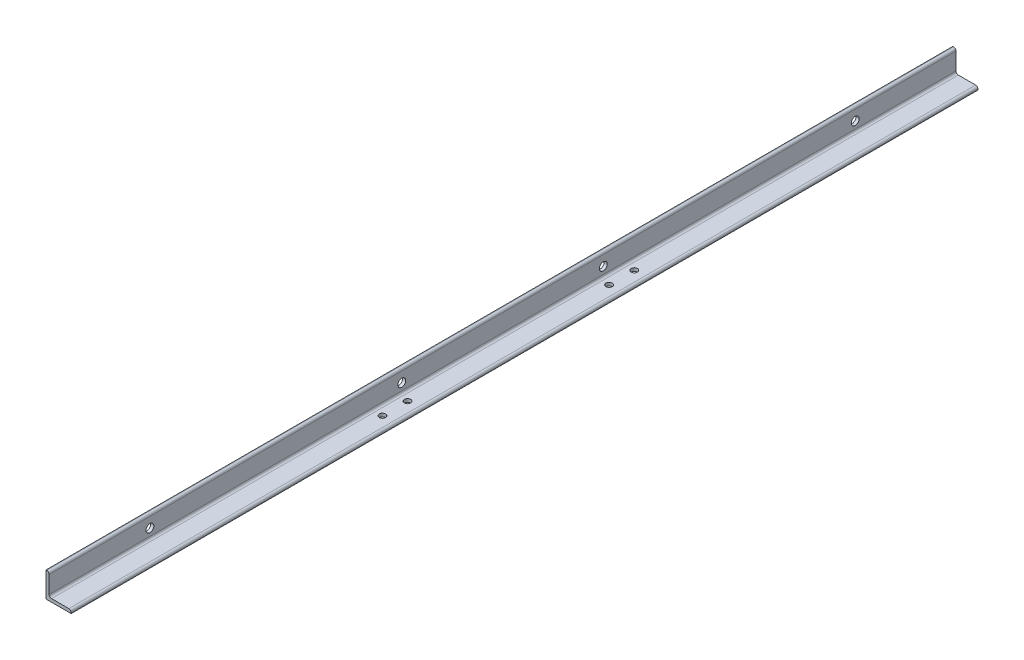
from build123d import *

# Parameters (mm, degrees)
BOSS_EXTRUDE1_DEPTH                 = 914.4
F_13_16_0_8125_DIAMETER_HOLE1_D     = 12.7
F_13_16_0_8125_DIAMETER_HOLE1_DEPTH = 6.35
F_5_8_0_625_DIAMETER_HOLE1_D        = 15.875
F_5_8_0_625_DIAMETER_HOLE1_DEPTH    = 6.35
SKETCH7_R                           = 6.35
CUT_EXTRUDE1_DEPTH                  = 7.35


with BuildPart() as part:
    # Sketch1 → Boss-Extrude1 (new body, symmetric)
    with BuildSketch(Plane.XY):
        with BuildLine():
            Line((0, 0), (0, 50.8))
            Line((0, 50.8), (1.59258, 50.8))
            ThreePointArc((1.59258, 50.8), (4.956583943, 49.406583943), (6.35, 46.04258))
            Line((6.35, 46.04258), (6.35, 11.1125))
            ThreePointArc((6.35, 11.1125), (7.744903955, 7.744903955), (11.1125, 6.35))
            Line((11.1125, 6.35), (46.04258, 6.35))
            ThreePointArc((46.04258, 6.35), (49.406583943, 4.956583943), (50.8, 1.59258))
            Line((50.8, 1.59258), (50.8, 0))
            Line((50.8, 0), (0, 0))
        make_face()
    extrude(amount=BOSS_EXTRUDE1_DEPTH, both=True)

    # 13/16 (0.8125) Diameter Hole1
    with Locations(Plane.XZ):
        with Locations((25.4, -195.834), (25.4, 210.566)):
            Hole(F_13_16_0_8125_DIAMETER_HOLE1_D / 2, depth=F_13_16_0_8125_DIAMETER_HOLE1_DEPTH)

    # 5/8 (0.625) Diameter Hole1
    with Locations(Plane.ZY):
        with Locations((-711.2, 25.4), (-203.2, 25.4), (203.2, 25.4), (711.2, 25.4)):
            Hole(F_5_8_0_625_DIAMETER_HOLE1_D / 2, depth=F_5_8_0_625_DIAMETER_HOLE1_DEPTH)

    # Sketch7 → Cut-Extrude1 (cut, through all)
    with BuildSketch(Plane(origin=(0, 6.35, 0), x_dir=(1, 0, 0), z_dir=(0, 1, 0))):
        with Locations((25.4, 246.634)):
            Circle(SKETCH7_R)
        with Locations((25.4, -261.366)):
            Circle(SKETCH7_R)
    extrude(amount=-CUT_EXTRUDE1_DEPTH, mode=Mode.SUBTRACT)


solid = part.part
